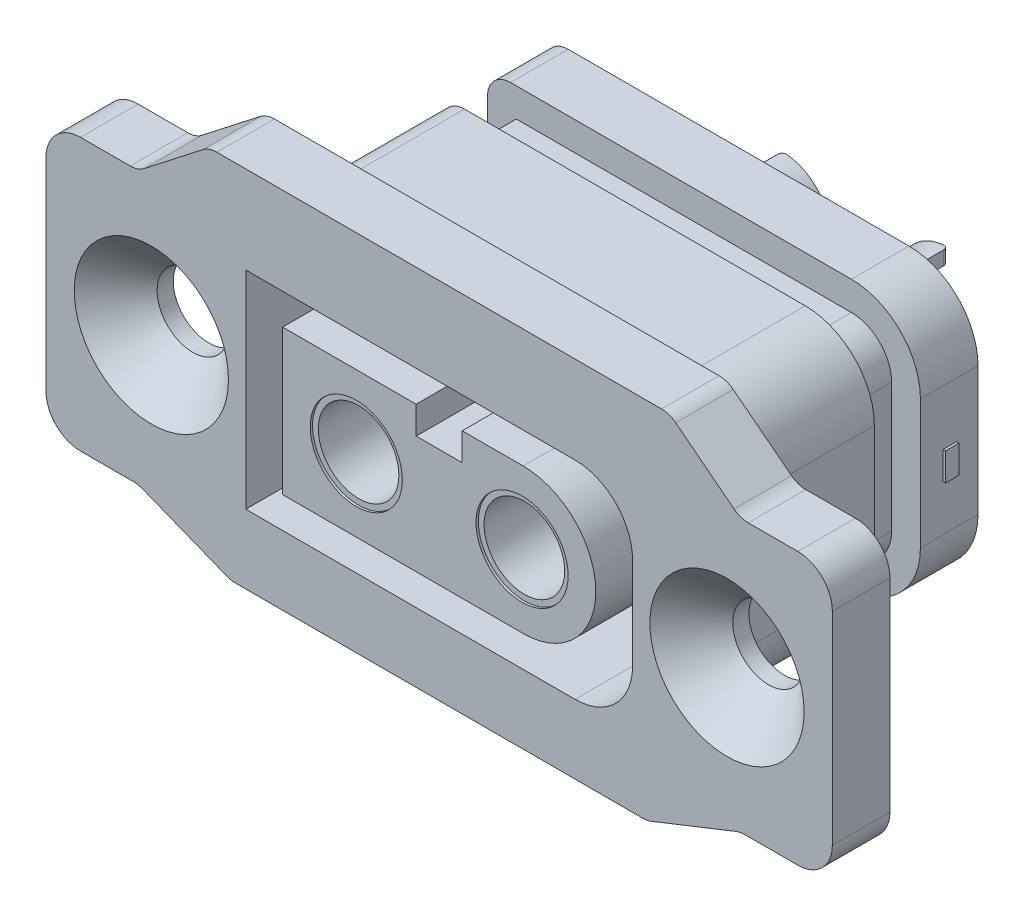
from build123d import *

# Parameters (mm, degrees)
SKETCH1_W                                            = 18.8
SKETCH1_H                                            = 11.6
BOSS_EXTRUDE1_DEPTH                                  = 11.5
SKETCH2_W                                            = 34.15
SKETCH2_H                                            = 11.8
BOSS_EXTRUDE2_DEPTH                                  = 2.5
BOSS_EXTRUDE3_DEPTH                                  = 2.5
FILLET1_R                                            = 1.5
FILLET2_R                                            = 1
CSK_FOR_M3_HEX_SOCKET_COUNTERSUNK_HEAD_S_D           = 3.1
CSK_FOR_M3_HEX_SOCKET_COUNTERSUNK_HEAD_S_CSINK_D     = 6.7
CSK_FOR_M3_HEX_SOCKET_COUNTERSUNK_HEAD_S_CSINK_ANGLE = 90
FILLET3_R                                            = 3
FILLET4_R                                            = 1
CUT_EXTRUDE1_DEPTH                                   = 2
SKETCH7_W                                            = 6.4
SKETCH7_H                                            = 6.2
CUT_EXTRUDE2_DEPTH                                   = 2
FILLET5_R                                            = 1.5
SKETCH8_R                                            = 2.1
BOSS_EXTRUDE4_DEPTH                                  = 6.5
F_3_0MM_DOWEL_HOLE1_D                                = 3
F_3_0MM_DOWEL_HOLE1_DEPTH                            = 3.3
F_3_0MM_DOWEL_HOLE1_TIP                              = 0.901290929
SKETCH11_W                                           = 3.39233295
SKETCH11_H                                           = 4.331282249
SKETCH11_W_2                                         = 2.756270522
SKETCH11_H_2                                         = 5.335422798
CUT_EXTRUDE3_DEPTH                                   = 3.25
FILLET6_R                                            = 0.2
CUT_EXTRUDE6_DEPTH                                   = 8.8
SKETCH13_R                                           = 2
CUT_EXTRUDE7_DEPTH                                   = 0.1
SKETCH14_R                                           = 1.75
CUT_EXTRUDE8_DEPTH                                   = 12
SKETCH15_W                                           = 0.583333334
SKETCH15_H                                           = 1.211538462
BOSS_EXTRUDE5_DEPTH                                  = 0.1
BOSS_EXTRUDE6_DEPTH                                  = 0.1


with BuildPart() as part:
    # Sketch1 → Boss-Extrude1 (new body)
    with BuildSketch(Plane.XY):
        Rectangle(SKETCH1_W, SKETCH1_H)
    extrude(amount=-BOSS_EXTRUDE1_DEPTH)

    # Sketch2 → Boss-Extrude2 (add)
    with BuildSketch(Plane.XY):
        Rectangle(SKETCH2_W, SKETCH2_H)
    extrude(amount=BOSS_EXTRUDE2_DEPTH)

    # Sketch3 → Boss-Extrude3 (add)
    with BuildSketch(Plane.XY):
        Polygon((-10, 8.3), (-13.075, 5.9), (-13.075, -5.9), (-9.036144578, -7.5), (9.036144578, -7.5), (13.075, -5.9), (13.075, 5.9), (10, 8.3), align=None)
    extrude(amount=BOSS_EXTRUDE3_DEPTH)

    # Fillet1
    fillet1_edges = [part.edges().sort_by_distance(p)[0] for p in [
        (-17.075, 5.9, 1.25),
        (-17.075, -5.9, 1.25),
        (17.075, -5.9, 1.25),
        (17.075, 5.9, 1.25),
    ]]
    fillet(fillet1_edges, radius=FILLET1_R)

    # Fillet2
    fillet2_edges = [part.edges().sort_by_distance(p)[0] for p in [
        (10, 8.3, 1.25),
        (-10, 8.3, 1.25),
        (-13.075, 5.9, 1.25),
        (-13.075, -5.9, 1.25),
        (-9.036144578, -7.5, 1.25),
        (9.036144578, -7.5, 1.25),
        (13.075, -5.9, 1.25),
        (13.075, 5.9, 1.25),
    ]]
    fillet(fillet2_edges, radius=FILLET2_R)

    # CSK for M3 Hex Socket Countersunk Head Screw1 (through all)
    with Locations(Plane.XY.offset(2.5)):
        with Locations((-12.5, 0), (12.5, 0)):
            CounterSinkHole(CSK_FOR_M3_HEX_SOCKET_COUNTERSUNK_HEAD_S_D / 2, CSK_FOR_M3_HEX_SOCKET_COUNTERSUNK_HEAD_S_CSINK_D / 2, counter_sink_angle=CSK_FOR_M3_HEX_SOCKET_COUNTERSUNK_HEAD_S_CSINK_ANGLE)

    # Fillet3
    fillet3_edges = [part.edges().sort_by_distance(p)[0] for p in [
        (9.4, 5.8, -5.75),
        (9.4, -5.8, -5.75),
    ]]
    fillet(fillet3_edges, radius=FILLET3_R)

    # Fillet4
    fillet4_edges = [part.edges().sort_by_distance(p)[0] for p in [
        (-9.4, 5.8, -5.75),
        (-9.4, -5.8, -5.75),
    ]]
    fillet(fillet4_edges, radius=FILLET4_R)

    # Sketch6 → Cut-Extrude1 (cut)
    with BuildSketch(Plane(origin=(0, 0, -7), x_dir=(-1, 0, 0), z_dir=(0, 0, -1))):
        with BuildLine():
            Line((-6.4, -6.7), (8.4, -6.7))
            ThreePointArc((8.4, -6.7), (9.743502884, -6.143502884), (10.3, -4.8))
            Line((10.3, -4.8), (10.3, 4.8))
            ThreePointArc((10.3, 4.8), (9.743502884, 6.143502884), (8.4, 6.7))
            Line((8.4, 6.7), (-6.4, 6.7))
            ThreePointArc((-6.4, 6.7), (-9.157716447, 5.557716447), (-10.3, 2.8))
            Line((-10.3, 2.8), (-10.3, -2.8))
            ThreePointArc((-10.3, -2.8), (-9.157716447, -5.557716447), (-6.4, -6.7))
        make_face()
        with BuildLine():
            Line((-6.4, -4.55), (8.15, -4.55))
            Line((8.15, -4.55), (8.15, 4.55))
            Line((8.15, 4.55), (-6.4, 4.55))
            ThreePointArc((-6.4, 4.55), (-7.637436867, 4.037436867), (-8.15, 2.8))
            Line((-8.15, 2.8), (-8.15, -2.8))
            ThreePointArc((-8.15, -2.8), (-7.637436867, -4.037436867), (-6.4, -4.55))
        make_face(mode=Mode.SUBTRACT)
    extrude(amount=CUT_EXTRUDE1_DEPTH, mode=Mode.SUBTRACT)

    # Sketch7 → Cut-Extrude2 (cut)
    with BuildSketch(Plane(origin=(0, 0, -11.5), x_dir=(-1, 0, 0), z_dir=(0, 0, -1))):
        with Locations((-3.5, 0)):
            Rectangle(SKETCH7_W, SKETCH7_H)
        with Locations((3.5, 0)):
            Rectangle(SKETCH7_W, SKETCH7_H)
    extrude(amount=-CUT_EXTRUDE2_DEPTH, mode=Mode.SUBTRACT)

    # Fillet5
    fillet5_edges = [part.edges().sort_by_distance(p)[0] for p in [
        (6.7, -3.1, -10.5),
        (6.7, 3.1, -10.5),
    ]]
    fillet(fillet5_edges, radius=FILLET5_R)

    # Sketch8 → Boss-Extrude4 (add)
    with BuildSketch(Plane(origin=(0, 0, -9.5), x_dir=(-1, 0, 0), z_dir=(0, 0, -1))):
        with Locations((-3.6, 0)):
            Circle(SKETCH8_R)
        with Locations((3.6, 0)):
            Circle(SKETCH8_R)
    extrude(amount=BOSS_EXTRUDE4_DEPTH)

    # Ø3.0mm Dowel Hole1
    with Locations(Plane(origin=(0, 0, -16), x_dir=(-1, 0, 0), z_dir=(0, 0, -1))):
        with Locations((-3.6, 0), (3.6, 0)):
            Hole(F_3_0MM_DOWEL_HOLE1_D / 2, depth=F_3_0MM_DOWEL_HOLE1_DEPTH)
            with Locations((0, 0, -(F_3_0MM_DOWEL_HOLE1_DEPTH + F_3_0MM_DOWEL_HOLE1_TIP / 2))):  # 118° drill point
                Cone(0, F_3_0MM_DOWEL_HOLE1_D / 2, F_3_0MM_DOWEL_HOLE1_TIP, mode=Mode.SUBTRACT)

    # Sketch11 → Cut-Extrude3 (cut, symmetric)
    with BuildSketch(Plane(origin=(0, 0, 0), x_dir=(1, 0, 0), z_dir=(0, 1, 0))):
        with Locations((-5.296166475, 15.165641125)):
            Rectangle(SKETCH11_W, SKETCH11_H)
        with Locations((4.978135261, 15.667711399)):
            Rectangle(SKETCH11_W_2, SKETCH11_H_2)
    extrude(amount=CUT_EXTRUDE3_DEPTH, both=True, mode=Mode.SUBTRACT)

    # Fillet6
    fillet6_edges = [part.edges().sort_by_distance(p)[0] for p in [
        (-3.6, 1.8, -13),
        (-3.6, -1.8, -13),
        (-3.6, 1.8, -16),
        (-3.6, -1.8, -16),
        (3.6, 1.8, -13),
        (3.6, -1.8, -13),
        (3.6, -1.8, -16),
        (3.6, 1.8, -16),
    ]]
    fillet(fillet6_edges, radius=FILLET6_R)

    # Sketch12 → Cut-Extrude6 (cut)
    with BuildSketch(Plane.XY.offset(2.5)):
        with BuildLine():
            Line((5.9, -4.5), (-8.4, -4.5))
            Line((-8.4, -4.5), (-8.4, 4.5))
            Line((-8.4, 4.5), (5.9, 4.5))
            ThreePointArc((5.9, 4.5), (7.667766953, 3.767766953), (8.4, 2))
            Line((8.4, 2), (8.4, -2))
            ThreePointArc((8.4, -2), (7.667766953, -3.767766953), (5.9, -4.5))
        make_face()
        with BuildLine():
            Line((3.65, -3.15), (-6.8, -3.15))
            Line((-6.8, -3.15), (-6.8, 3.15))
            Line((-6.8, 3.15), (-1, 3.15))
            Line((-1, 3.15), (-1, 1.95))
            Line((-1, 1.95), (1, 1.95))
            Line((1, 1.95), (1, 3.15))
            Line((1, 3.15), (3.65, 3.15))
            ThreePointArc((3.65, 3.15), (6.8, 0), (3.65, -3.15))
        make_face(mode=Mode.SUBTRACT)
    extrude(amount=-CUT_EXTRUDE6_DEPTH, mode=Mode.SUBTRACT)

    # Sketch13 → Cut-Extrude7 (cut)
    with BuildSketch(Plane.XY.offset(2.5)):
        with Locations((-3.6, 0)):
            Circle(SKETCH13_R)
        with Locations((3.6, 0)):
            Circle(SKETCH13_R)
    extrude(amount=-CUT_EXTRUDE7_DEPTH, mode=Mode.SUBTRACT)

    # Sketch14 → Cut-Extrude8 (cut)
    with BuildSketch(Plane.XY.offset(2.5)):
        with Locations((-3.6, 0)):
            Circle(SKETCH14_R)
        with Locations((3.6, 0)):
            Circle(SKETCH14_R)
    extrude(amount=-CUT_EXTRUDE8_DEPTH, mode=Mode.SUBTRACT)

    # Sketch15 → Boss-Extrude5 (add)
    with BuildSketch(Plane(origin=(9.4, 0, 0), x_dir=(0, 0, -1), z_dir=(1, 0, 0))):
        with Locations((10.278846154, -0.201923077)):
            Rectangle(SKETCH15_W, SKETCH15_H)
    extrude(amount=BOSS_EXTRUDE5_DEPTH)

    # Sketch16 → Boss-Extrude6 (add)
    with BuildSketch(Plane.ZY.offset(9.4)):
        Polygon((-10.560064901, -0.314102564), (-11.412629003, -0.314102564), (-11.412629003, 0.269230769), (-10.560064901, 0.269230769), (-10.560064901, 1.166666667), (-9.976731567, 1.166666667), (-9.976731567, 0.269230769), (-9.124167465, 0.269230769), (-9.124167465, -0.314102564), (-9.976731567, -0.314102564), (-9.976731567, -1.211538462), (-10.560064901, -1.211538462), align=None)
    extrude(amount=BOSS_EXTRUDE6_DEPTH)


solid = part.part
